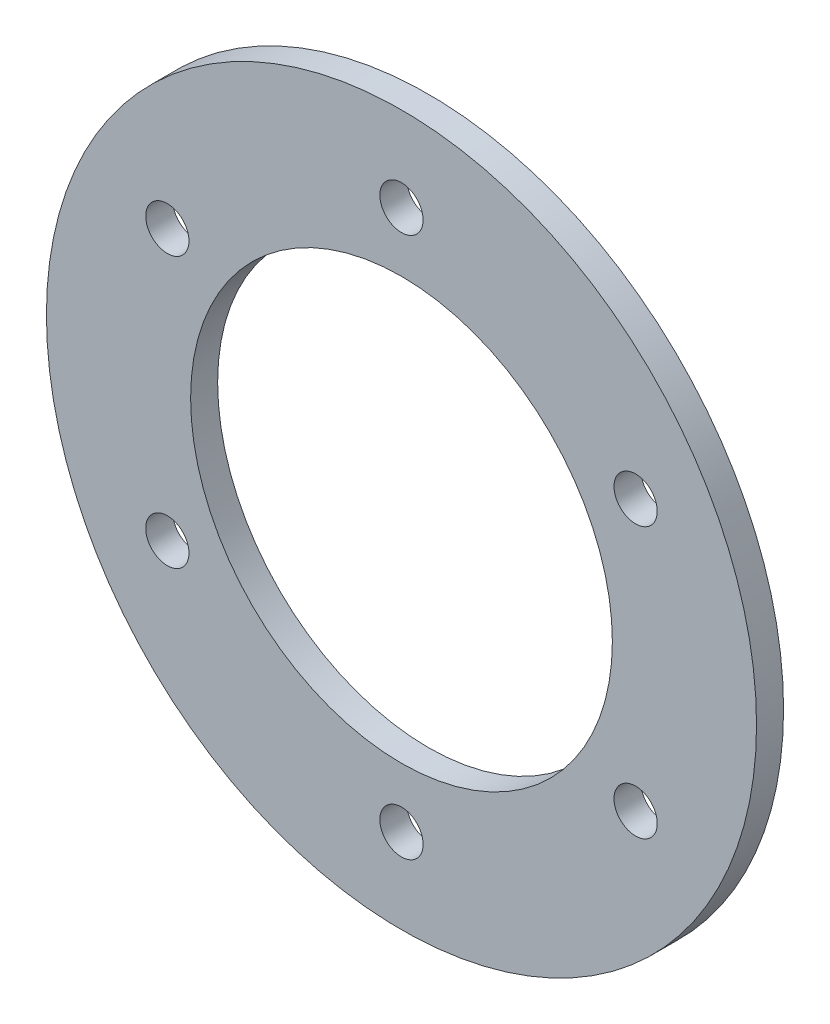
from build123d import *

# Parameters (mm, degrees)
SKETCH1_R                = 19.7
SKETCH1_R_2              = 11.7
BOSS_EXTRUDE1_DEPTH      = 0.75
M2_CLEARANCE_HOLE1_D     = 2.4
M2_CLEARANCE_HOLE1_DEPTH = 1.5


with BuildPart() as part:
    # Sketch1 → Boss-Extrude1 (new body, symmetric)
    with BuildSketch(Plane.XY):
        Circle(SKETCH1_R)
        Circle(SKETCH1_R_2, mode=Mode.SUBTRACT)
    extrude(amount=BOSS_EXTRUDE1_DEPTH, both=True)

    # M2 Clearance Hole1
    with Locations(Plane.XY.offset(0.75)):
        with Locations((-12.990381057, 7.5), (0, 15), (12.990381057, 7.5), (12.990381057, -7.5), (0, -15), (-12.990381057, -7.5)):
            Hole(M2_CLEARANCE_HOLE1_D / 2, depth=M2_CLEARANCE_HOLE1_DEPTH)


solid = part.part
